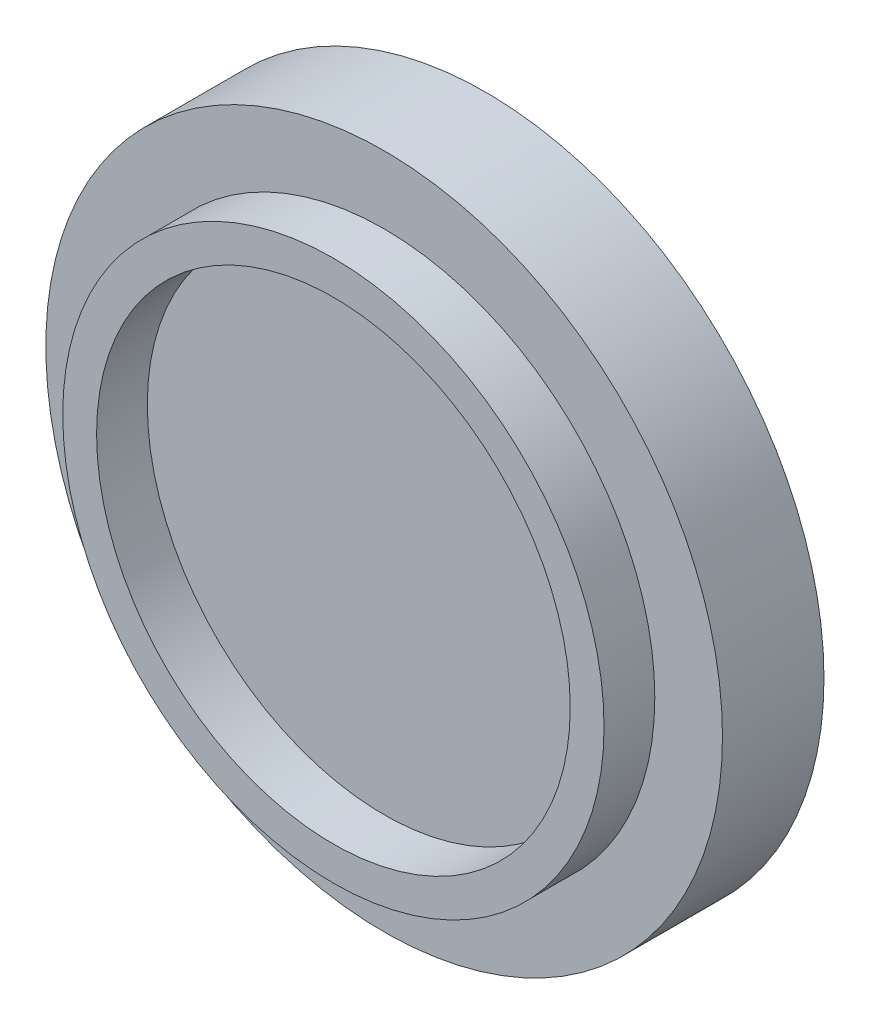
from build123d import *

# Parameters (mm, degrees)
SZKIC1_R                    = 100
DODANIE_WYCI_GNI_CIE1_DEPTH = 30
SZKIC2_R                    = 80
SZKIC2_R_2                  = 70
DODANIE_WYCI_GNI_CIE2_DEPTH = 15


with BuildPart() as part:
    # Szkic1 → Dodanie-wyciągnięcie1 (new body)
    with BuildSketch(Plane.XY):
        Circle(SZKIC1_R)
    extrude(amount=DODANIE_WYCI_GNI_CIE1_DEPTH)

    # Szkic2 → Dodanie-wyciągnięcie2 (add)
    with BuildSketch(Plane.XY.offset(30)):
        Circle(SZKIC2_R)
        Circle(SZKIC2_R_2, mode=Mode.SUBTRACT)
    extrude(amount=DODANIE_WYCI_GNI_CIE2_DEPTH)


solid = part.part
